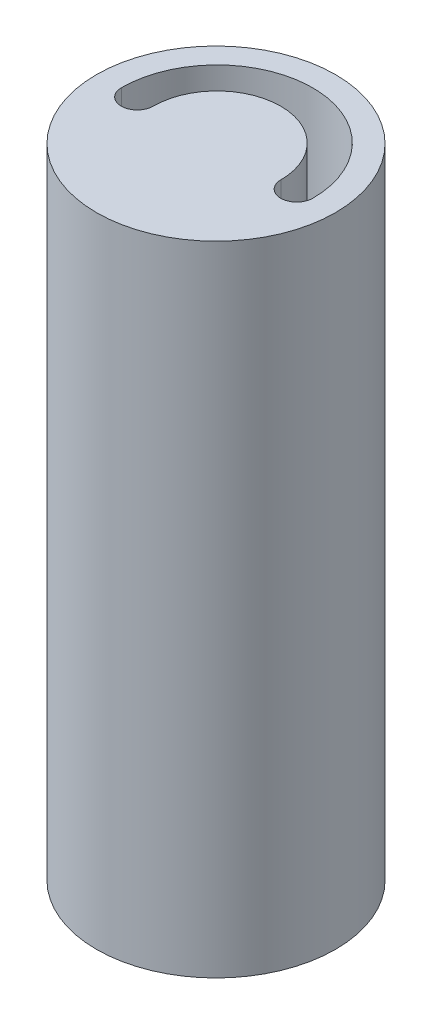
from build123d import *

# Parameters (mm, degrees)
SKETCH1_R           = 28.1
BOSS_EXTRUDE2_DEPTH = 61.3
SKETCH3_R           = 18.6
CUT_EXTRUDE2_DEPTH  = 58.8
SKETCH4_W           = 56.2
SKETCH4_H           = 56.2
BOSS_EXTRUDE3_DEPTH = 56.2
SKETCH5_R           = 16.1
CUT_EXTRUDE4_DEPTH  = 5
SKETCH6_W           = 49.797391422
SKETCH6_H           = 49.779255452
CUT_EXTRUDE5_DEPTH  = 53.7
SKETCH7_R           = 28.1
BOSS_EXTRUDE4_DEPTH = 321.5
CUT_EXTRUDE6_DEPTH  = 10
SKETCH9_R           = 3
CUT_EXTRUDE7_DEPTH  = 1
SKETCH10_R          = 6.025
CUT_EXTRUDE8_DEPTH  = 0.1
SKETCH18_R          = 3.75
CUT_EXTRUDE9_DEPTH  = 100
SKETCH19_R          = 3.75
CUT_EXTRUDE11_DEPTH = 325
SKETCH20_W          = 56.2
SKETCH20_H          = 56.2
CUT_EXTRUDE13_DEPTH = 200
SKETCH22_R          = 28.332078896
CUT_EXTRUDE15_DEPTH = 171.5


with BuildPart() as part:
    # Sketch1 → Boss-Extrude2 (new body)
    with BuildSketch(Plane.XY):
        Circle(SKETCH1_R)
    extrude(amount=BOSS_EXTRUDE2_DEPTH)

    # Sketch3 → Cut-Extrude2 (cut)
    with BuildSketch(Plane.XY.offset(61.3)):
        with Locations((0, -7)):
            Circle(SKETCH3_R)
    extrude(amount=-CUT_EXTRUDE2_DEPTH, mode=Mode.SUBTRACT)

    # Sketch4 → Boss-Extrude3 (add)
    with BuildSketch(Plane(origin=(0, 0, 0), x_dir=(-1, 0, 0), z_dir=(0, 0, -1))):
        Rectangle(SKETCH4_W, SKETCH4_H)
    extrude(amount=BOSS_EXTRUDE3_DEPTH)

    # Sketch5 → Cut-Extrude4 (cut)
    with BuildSketch(Plane.XY.offset(2.5)):
        with Locations((0, -7)):
            Circle(SKETCH5_R)
    extrude(amount=-CUT_EXTRUDE4_DEPTH, mode=Mode.SUBTRACT)

    # Sketch6 → Cut-Extrude5 (cut)
    with BuildSketch(Plane(origin=(0, 0, -56.2), x_dir=(-1, 0, 0), z_dir=(0, 0, -1))):
        Rectangle(SKETCH6_W, SKETCH6_H)
    extrude(amount=-CUT_EXTRUDE5_DEPTH, mode=Mode.SUBTRACT)

    # Sketch7 → Boss-Extrude4 (add)
    with BuildSketch(Plane(origin=(0, -28.1, 0), x_dir=(-1, 0, 0), z_dir=(0, -1, 0))):
        with Locations(Location((0, 28.1, 0), (0, 0, 90))):
            Circle(SKETCH7_R)
    extrude(amount=BOSS_EXTRUDE4_DEPTH)

    # Sketch8 → Cut-Extrude6 (cut)
    with BuildSketch(Plane(origin=(0, -349.6, 0), x_dir=(-1, 0, 0), z_dir=(0, -1, 0))):
        with BuildLine():
            Line((-1.658312395, 25.832078896), (1.658312395, 25.832078896))
            ThreePointArc((1.658312395, 25.832078896), (3, 28.332078896), (1.658312395, 30.832078896))
            Line((1.658312395, 30.832078896), (-1.658312395, 30.832078896))
            ThreePointArc((-1.658312395, 30.832078896), (-3, 28.332078896), (-1.658312395, 25.832078896))
        make_face()
    extrude(amount=-CUT_EXTRUDE6_DEPTH, mode=Mode.SUBTRACT)

    # Sketch9 → Cut-Extrude7 (cut)
    with BuildSketch(Plane(origin=(0, -349.6, 0), x_dir=(-1, 0, 0), z_dir=(0, -1, 0))):
        with Locations(Location((0, 28.332078896, 0), (0, 0, 90))):
            Circle(SKETCH9_R)
    extrude(amount=-CUT_EXTRUDE7_DEPTH, mode=Mode.SUBTRACT)

    # Sketch10 → Cut-Extrude8 (cut)
    with BuildSketch(Plane(origin=(0, -349.6, 0), x_dir=(-1, 0, 0), z_dir=(0, -1, 0))):
        with Locations(Location((0, 28.332078896, 0), (0, 0, 90))):
            Circle(SKETCH10_R)
    extrude(amount=-CUT_EXTRUDE8_DEPTH, mode=Mode.SUBTRACT)

    # Cut-Sweep4: sweep along a path in Sketch15
    with BuildLine(Plane(origin=(0, -349.6, 0), x_dir=(-1, 0, 0), z_dir=(0, -1, 0))) as cut_sweep4_path:
        ThreePointArc((15, 28.332078896), (0, 43.332078896), (-15, 28.332078896))
    # 3DSketch2 → Cut-Sweep4 (sweep, cut)
    with BuildSketch(Plane(origin=(-15, -349.6, -28.332078896), x_dir=(-0.022748965612757834, 0.999741208795331, 0), z_dir=(0, 0, 1))):
        Polygon((0, 0), (0.170617242, 7.498059066), (329.685319661, 0), (329.514702419, -7.498059066), align=None)
    sweep(path=cut_sweep4_path.line, mode=Mode.SUBTRACT)

    # Sketch18 → Cut-Extrude9 (cut)
    with BuildSketch(Plane.XY.offset(61.3)):
        with Locations((0, 18.75)):
            Circle(SKETCH18_R)
    extrude(amount=-CUT_EXTRUDE9_DEPTH, mode=Mode.SUBTRACT)

    # Sketch19 → Cut-Extrude11 (cut)
    with BuildSketch(Plane(origin=(0, -349.6, 0), x_dir=(-1, 0, 0), z_dir=(0, -1, 0))):
        with Locations((-18.75, 28.332078896)):
            Circle(SKETCH19_R)
        with Locations((18.75, 28.332078896)):
            Circle(SKETCH19_R)
    extrude(amount=-CUT_EXTRUDE11_DEPTH, mode=Mode.SUBTRACT)

    # Sketch20 → Cut-Extrude13 (cut)
    with BuildSketch(Plane(origin=(0, 0, -56.2), x_dir=(-1, 0, 0), z_dir=(0, 0, -1))):
        Rectangle(SKETCH20_W, SKETCH20_H)
    extrude(amount=-CUT_EXTRUDE13_DEPTH, mode=Mode.SUBTRACT)

    # Sketch22 → Cut-Extrude15 (cut)
    with BuildSketch(Plane(origin=(0, -349.6, 0), x_dir=(-1, 0, 0), z_dir=(0, -1, 0))):
        with Locations((0, 28.332078896)):
            Circle(SKETCH22_R)
    extrude(amount=-CUT_EXTRUDE15_DEPTH, mode=Mode.SUBTRACT)


solid = part.part
